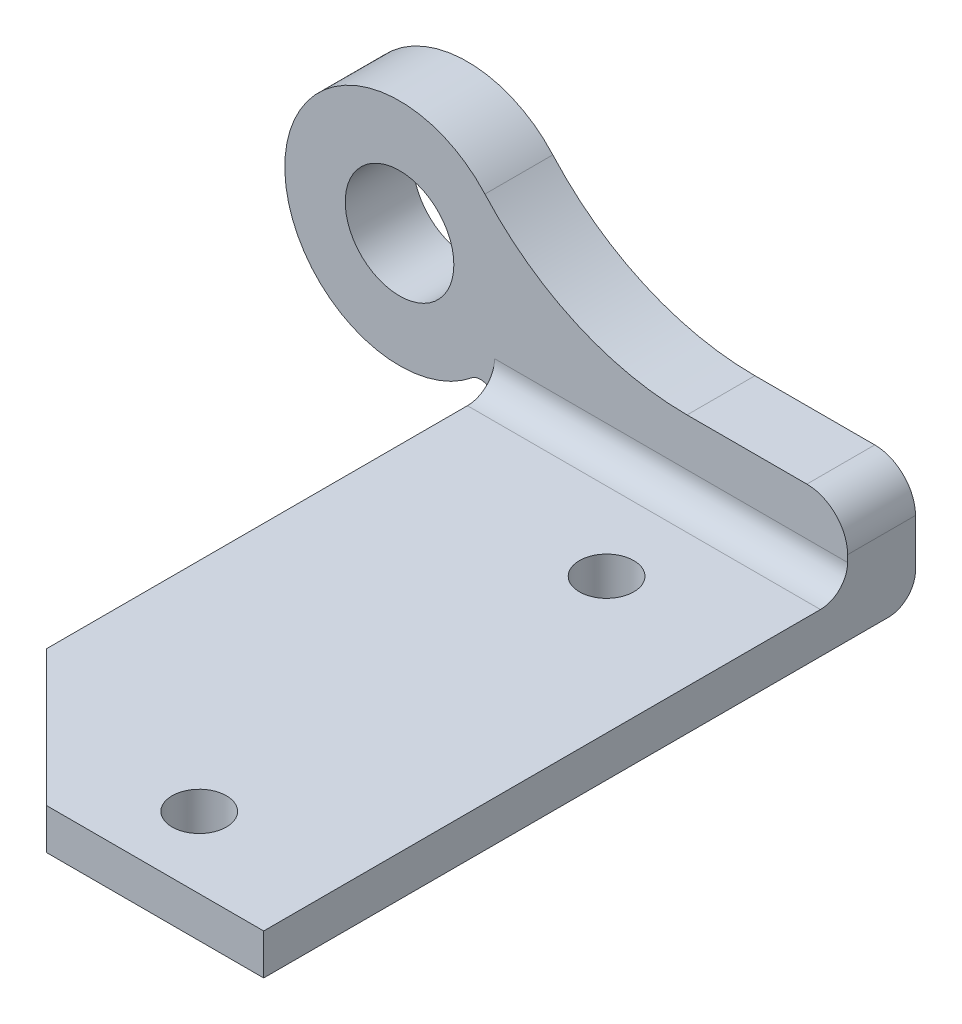
from build123d import *

# Parameters (mm, degrees)
EXTRUDE_1_DEPTH      = 3
EXTRUDE_1_DEPTH_BACK = 2
SKETCH_2_R           = 2
EXTRUDE_2_DEPTH      = 3
FILLET_1_R           = 2
CHAMFER_1_SIZE2      = 10.001839768
CHAMFER_1_SIZE       = 10
FILLET_2_R           = 2


with BuildPart() as part:
    # 草图1 → 凸台-拉伸1 (new body, two sides)
    with BuildSketch(Plane.XY) as extrude_1_sk:
        with BuildLine():
            ThreePointArc((-6.1689615, -8.116064678), (0.566562607, -13.023133247), (8.717166108, -14.759298421))
            Line((8.717166108, -14.759298421), (17.541649585, -14.759298421))
            ThreePointArc((17.541649585, -14.759298421), (19.662969929, -15.637978077), (20.541649585, -17.759298421))
            Line((20.541649585, -17.759298421), (20.541649585, -21.259298421))
            Line((20.541649585, -21.259298421), (-5.458350415, -21.259298421))
            Line((-5.458350415, -21.259298421), (-5.458350415, -21.060154535))
            ThreePointArc((-5.458350415, -21.060154535), (-6.052483902, -20.201263808), (-7.093271049, -20.287577169))
            ThreePointArc((-7.093271049, -20.287577169), (-20.884089955, -13.119444375), (-6.1689615, -8.116064678))
        make_face()
        with BuildLine():
            ThreePointArc((-12.458350415, -17.759298421), (-8.458350415, -13.759298421), (-12.458350415, -9.759298421))
            ThreePointArc((-12.458350415, -9.759298421), (-16.458350415, -13.759298421), (-12.458350415, -17.759298421))
        make_face(mode=Mode.SUBTRACT)
        Polygon((18.541649585, -23.259298421), (-3.458350415, -23.259298421), (-5.458350415, -23.259298421), (-5.458350415, -21.259298421), (20.541649585, -21.259298421), (20.541649585, -23.259298421), align=None)
    extrude(amount=EXTRUDE_1_DEPTH)
    extrude(extrude_1_sk.sketch, amount=-EXTRUDE_1_DEPTH_BACK)

    # 草图2 → 凸台-拉伸2 (add)
    with BuildSketch(Plane.XZ.offset(23.259298421)):
        Polygon((20.541649585, 46.004782855), (-5.458350415, 46.000000778), (-5.458350415, 2), (-5.458350415, -2), (20.541649585, -2), align=None)
        with Locations((10.541649585, 40.750439451)):
            Circle(SKETCH_2_R, mode=Mode.SUBTRACT)
        with Locations((10.541649585, 10.750439451)):
            Circle(SKETCH_2_R, mode=Mode.SUBTRACT)
    extrude(amount=-EXTRUDE_2_DEPTH)

    # 圆角1
    fillet_1_edges = [part.edges().sort_by_distance(p)[0] for p in [
        (7.541649585, -23.259298421, -2),
    ]]
    fillet(fillet_1_edges, radius=FILLET_1_R)

    # 倒角1
    chamfer_1_edges = [part.edges().sort_by_distance(p)[0] for p in [
        (-5.458350415, -21.759298421, 46.000000778),
    ]]
    chamfer(chamfer_1_edges, length=CHAMFER_1_SIZE, length2=CHAMFER_1_SIZE2)

    # 圆角2
    fillet_2_edges = [part.edges().sort_by_distance(p)[0] for p in [
        (7.541649585, -20.259298421, 3),
    ]]
    fillet(fillet_2_edges, radius=FILLET_2_R)


solid = part.part
